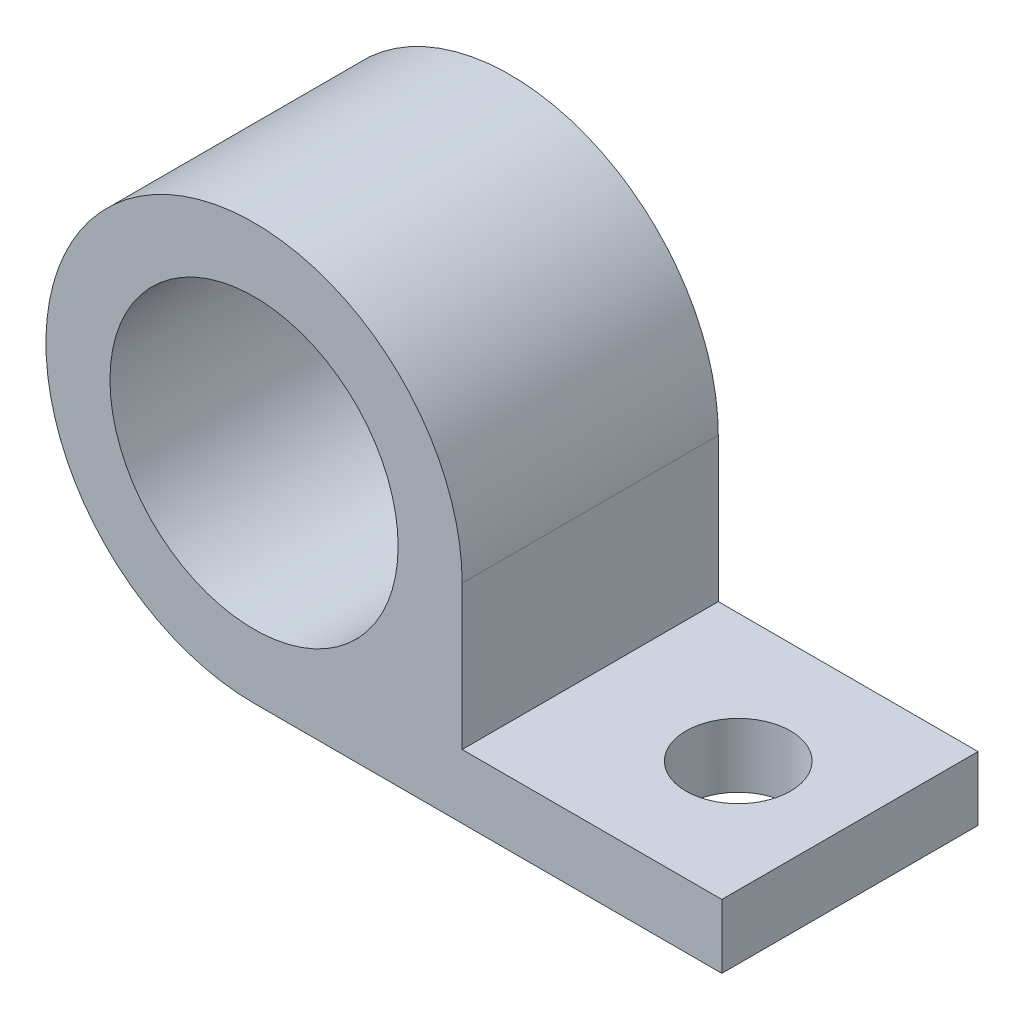
from build123d import *

# Parameters (mm, degrees)
SKETCH1_R           = 7.14375
BOSS_EXTRUDE1_DEPTH = 6.35
SKETCH2_R           = 2.5908
CUT_EXTRUDE1_DEPTH  = 11.31875


with BuildPart() as part:
    # Sketch1 → Boss-Extrude1 (new body, symmetric)
    with BuildSketch(Plane.XY):
        with BuildLine():
            Line((0, -10.31875), (23.19528, -10.31875))
            Line((23.19528, -10.31875), (23.19528, -7.14375))
            Line((23.19528, -7.14375), (10.31875, -7.14375))
            Line((10.31875, -7.14375), (10.31875, 0))
            ThreePointArc((10.31875, 0), (-7.296458098, 7.296458098), (0, -10.31875))
        make_face()
        Circle(SKETCH1_R, mode=Mode.SUBTRACT)
    extrude(amount=BOSS_EXTRUDE1_DEPTH, both=True)

    # Sketch2 → Cut-Extrude1 (cut, through all)
    with BuildSketch(Plane(origin=(0, 0, 0), x_dir=(1, 0, 0), z_dir=(0, 1, 0))):
        with Locations(Location((17.65808, 0, 0), (0, 0, 270))):  # turned: the seam where the file's is
            Circle(SKETCH2_R)
    extrude(amount=-CUT_EXTRUDE1_DEPTH, mode=Mode.SUBTRACT)


solid = part.part
